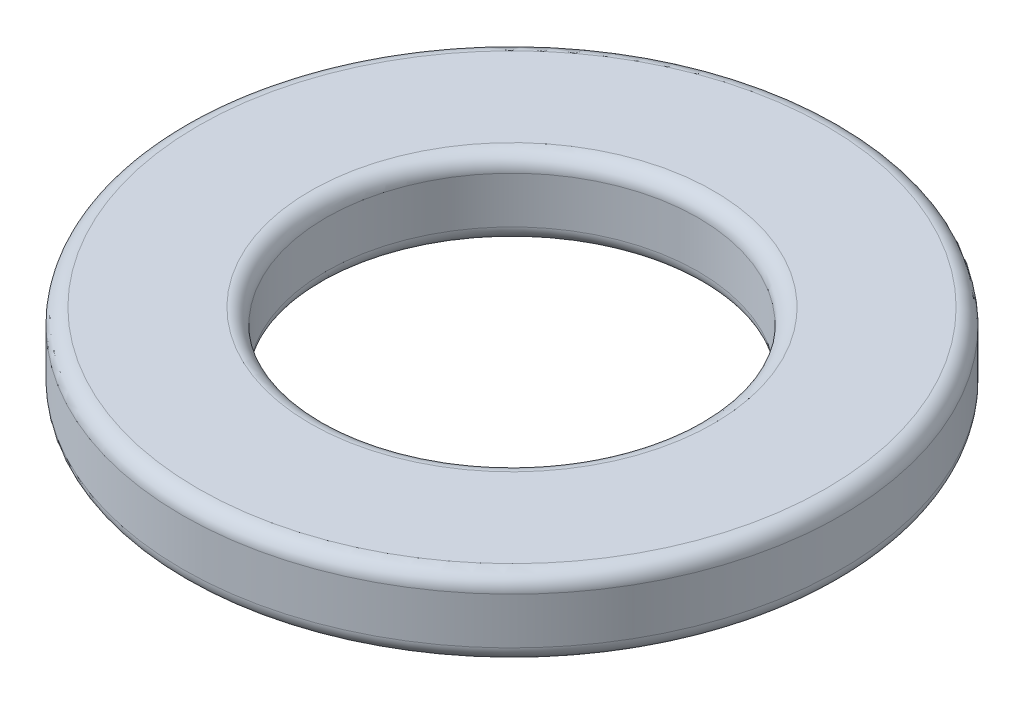
from build123d import *

# Parameters (mm, degrees)
SKETCH1_R           = 4.25
SKETCH1_R_2         = 2.4
BOSS_EXTRUDE1_DEPTH = 1
FILLET1_R           = 0.2


with BuildPart() as part:
    # Sketch1 → Boss-Extrude1 (new body)
    with BuildSketch(Plane(origin=(0, 0, 0), x_dir=(1, 0, 0), z_dir=(0, 1, 0))):
        Circle(SKETCH1_R)
        Circle(SKETCH1_R_2, mode=Mode.SUBTRACT)
    extrude(amount=BOSS_EXTRUDE1_DEPTH)

    # Fillet1
    fillet1_edges = [part.edges().sort_by_distance(p)[0] for p in [
        (-2.4, 0, 0),
        (-4.25, 0, 0),
        (-4.25, 1, 0),
        (-2.4, 1, 0),
    ]]
    fillet(fillet1_edges, radius=FILLET1_R)


solid = part.part
